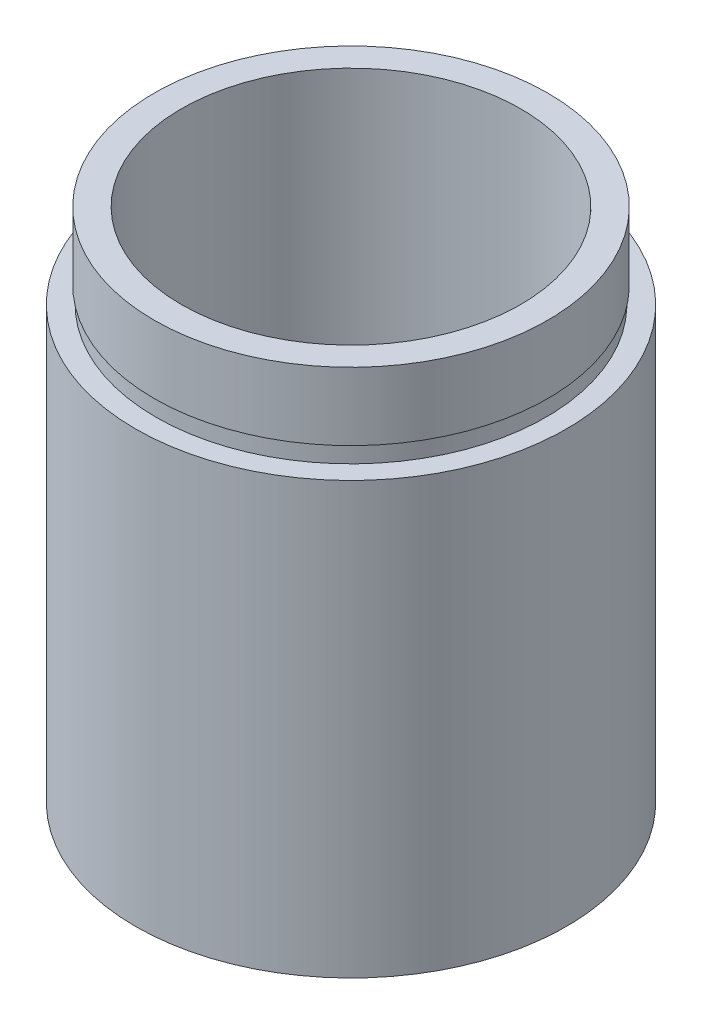
from build123d import *


with BuildPart() as part:
    # 草图1 → 旋转1 (revolve)
    with BuildSketch(Plane.XY, mode=Mode.PRIVATE) as revolve_1_sk:
        Polygon((12.7, 0), (12.7, 25.4), (11.5, 25.4), (11.5, 26.4), (11.6, 26.4), (11.6, 30.4), (10, 30.4), (10, 5.5), (11.7, 5.5), (11.7, 4.5), (11.1, 4.5), (11.1, 0), align=None)
    revolve(revolve_1_sk.sketch.rotate(Axis((0, 161.376166943, 0), (0, -1, 0)), 90), axis=Axis((0, 161.376166943, 0), (0, -1, 0)))  # turned: the seam where the file's is


solid = part.part
